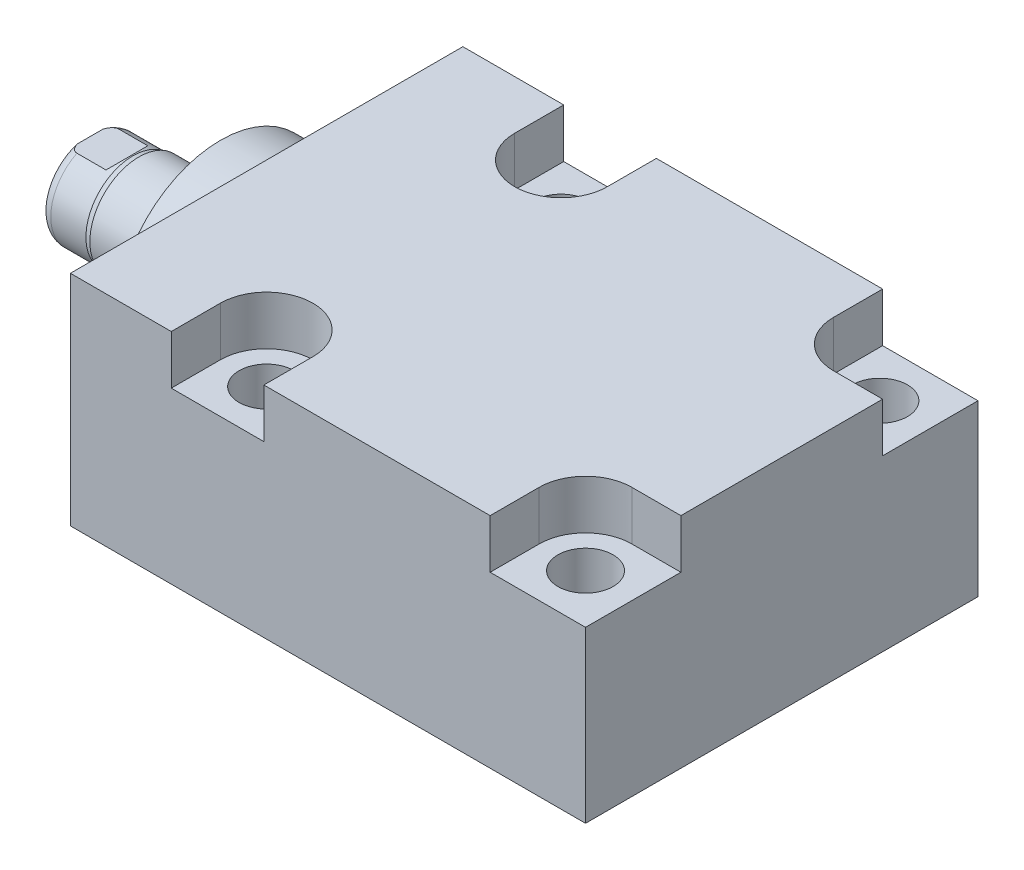
from build123d import *

# Parameters (mm, degrees)
SKETCH1_W          = 50.8
SKETCH1_H          = 28.321
EXTRUDE1_DEPTH     = 66.675
SKETCH5_R          = 13.5001
EXTRUDE2_DEPTH     = 5.969
SKETCH6_W          = 6.35
SKETCH6_H          = 16.891
CUT_EXTRUDE4_DEPTH = 30.48
HOLE2_D            = 7.1374
HOLE2_DEPTH        = 28.321
LPATTERN1_COUNT    = 2
LPATTERN1_PITCH    = 41.275
CUT_EXTRUDE5_DEPTH = 6.35
HOLE3_D            = 2.3876
HOLE3_DEPTH        = 14.224
HOLE3_CBORE_D      = 11.3411
HOLE3_CBORE_DEPTH  = 1.4478
HOLE3_TIP          = 0.717307407
HOLE4_D            = 3.175
HOLE4_DEPTH        = 14.224
HOLE4_TIP          = 0.953866233
SKETCH25_R         = 5.6705
CUT_EXTRUDE6_DEPTH = 1.448
CHAMFER1_SIZE      = 0.635
SKETCH23_R         = 1.4478
LPATTERN3_COUNT    = 2
LPATTERN3_PITCH    = 41.275


with BuildPart() as part:
    # Sketch1 → Extrude1 (new body)
    with BuildSketch(Plane(origin=(0, 0, 0), x_dir=(0, 0, -1), z_dir=(1, 0, 0))):
        with Locations((0, 0.1105)):
            Rectangle(SKETCH1_W, SKETCH1_H)
    extrude(amount=EXTRUDE1_DEPTH)

    # Sketch5 → Extrude2 (add)
    with BuildSketch(Plane.ZY):
        with Locations(Location((0, 0, 0), (0, 0, 180))):  # turned: the seam where the file's is
            Circle(SKETCH5_R)
    extrude(amount=EXTRUDE2_DEPTH)

    # Sketch6 → Revolve1 (revolve)
    with BuildSketch(Plane(origin=(0, 0, 0), x_dir=(0, 0, 1), z_dir=(0, -1, 0))):
        with Locations((-3.175, 14.4145)):
            Rectangle(SKETCH6_W, SKETCH6_H)
    revolve(axis=Axis((5.754582971, 0, 0), (-1, 0, 0)))

    # S2D0001 → Cut-Revolve4 (revolve, cut)
    with BuildSketch(Plane(origin=(-18.511260017, 3.2639, 0), x_dir=(0, 1, 0), z_dir=(0, 0, 1)), mode=Mode.PRIVATE) as cut_revolve4_sk:
        Polygon((-0.7112, 2.786949769), (-0.7112, -11.653260017), (-3.2639, -13.18707692), (-3.2639, 4.348739983), (0.1905, 4.348739983), align=None)
    revolve(cut_revolve4_sk.sketch.rotate(Axis((0, 0, 0), (-1, 0, 0)), 90), axis=Axis((0, 0, 0), (-1, 0, 0)), mode=Mode.SUBTRACT)  # turned: the seam where the file's is

    # Sketch8 → Cut-Revolve5 (revolve, cut)
    with BuildSketch(Plane(origin=(0, 0, 0), x_dir=(0, 0, -1), z_dir=(0, 1, 0)), mode=Mode.PRIVATE) as cut_revolve5_sk:
        with BuildLine():
            Line((-6.35, 16.5354), (-6.096, 17.2974))
            Line((-6.096, 17.2974), (-6.096, 21.844))
            ThreePointArc((-6.096, 21.844), (-5.995678675, 22.387796865), (-5.707922533, 22.86))
            Line((-5.707922533, 22.86), (-6.35, 22.86))
            Line((-6.35, 22.86), (-6.35, 16.5354))
        make_face()
    revolve(cut_revolve5_sk.sketch.rotate(Axis((-12.65936, 0, 0), (-1, 0, 0)), 180), axis=Axis((-12.65936, 0, 0), (-1, 0, 0)), mode=Mode.SUBTRACT)  # turned: the seam where the file's is

    # Sketch12 → Cut-Extrude4 (cut, symmetric)
    with BuildSketch(Plane(origin=(0, 0, 0), x_dir=(0, -1, 0), z_dir=(0, 0, -1))):
        Polygon((5.461, 22.86), (5.461, 18.0848), (6.096, 17.4498), (6.096, 22.86), align=None)
        Polygon((-5.461, 22.86), (-5.461, 18.0848), (-6.096, 17.4498), (-6.096, 22.86), align=None)
    extrude(amount=CUT_EXTRUDE4_DEPTH, both=True, mode=Mode.SUBTRACT)

    # Hole2
    with Locations(Plane(origin=(0, 14.271, 0), x_dir=(-1, 0, 0), z_dir=(0, 1, 0))):
        with Locations((-19.05, -19.05), (-19.05, 19.05)):
            hole2 = Hole(HOLE2_D / 2, depth=HOLE2_DEPTH)

    # LPattern1: Hole2 ×2
    with Locations(*[(i * LPATTERN1_PITCH, 0, 0) for i in range(1, LPATTERN1_COUNT)]):
        add(hole2, mode=Mode.SUBTRACT)

    # Sketch18 → Cut-Extrude5 (cut)
    with BuildSketch(Plane(origin=(0, 14.271, 0), x_dir=(1, 0, 0), z_dir=(0, 1, 0))):
        with BuildLine():
            Line((66.675, -25.4), (54.3306, -25.4))
            Line((54.3306, -25.4), (54.3306, -19.05))
            ThreePointArc((54.3306, -19.05), (56.086319111, -14.811319111), (60.325, -13.0556))
            Line((60.325, -13.0556), (66.675, -13.0556))
            Line((66.675, -13.0556), (66.675, -25.4))
        make_face()
        with BuildLine():
            Line((13.0556, -19.05), (13.0556, -25.4))
            Line((13.0556, -25.4), (25.0444, -25.4))
            Line((25.0444, -25.4), (25.0444, -19.05))
            ThreePointArc((25.0444, -19.05), (19.05, -13.0556), (13.0556, -19.05))
        make_face()
        with BuildLine():
            Line((66.675, 13.0556), (66.675, 25.4))
            Line((66.675, 25.4), (54.3306, 25.4))
            Line((54.3306, 25.4), (54.3306, 19.05))
            ThreePointArc((54.3306, 19.05), (56.086319111, 14.811319111), (60.325, 13.0556))
            Line((60.325, 13.0556), (66.675, 13.0556))
        make_face()
        with BuildLine():
            Line((25.0444, 25.4), (13.0556, 25.4))
            Line((13.0556, 25.4), (13.0556, 19.05))
            ThreePointArc((13.0556, 19.05), (19.05, 13.0556), (25.0444, 19.05))
            Line((25.0444, 19.05), (25.0444, 25.4))
        make_face()
    extrude(amount=-CUT_EXTRUDE5_DEPTH, mode=Mode.SUBTRACT)

    # Hole3
    with Locations(Plane.XZ.offset(14.05)):
        with Locations((12.7, 0)):
            CounterBoreHole(HOLE3_D / 2, HOLE3_CBORE_D / 2, HOLE3_CBORE_DEPTH, depth=HOLE3_DEPTH)
            with Locations((0, 0, -(HOLE3_DEPTH + HOLE3_TIP / 2))):  # 118° drill point
                Cone(0, HOLE3_D / 2, HOLE3_TIP, mode=Mode.SUBTRACT)

    # Hole4
    with Locations(Plane.XZ.offset(14.05)):
        with Locations((55.425, 0)):
            Hole(HOLE4_D / 2, depth=HOLE4_DEPTH)
            with Locations((0, 0, -(HOLE4_DEPTH + HOLE4_TIP / 2))):  # 118° drill point
                Cone(0, HOLE4_D / 2, HOLE4_TIP, mode=Mode.SUBTRACT)

    # Sketch25 → Cut-Extrude6 (cut)
    with BuildSketch(Plane.XZ.offset(14.05)):
        with Locations(Location((53.975, 0, 0), (0, 0, 270))):  # turned: the seam where the file's is
            Circle(SKETCH25_R)
    extrude(amount=-CUT_EXTRUDE6_DEPTH, mode=Mode.SUBTRACT)

    # Chamfer1
    chamfer1_edges = [part.edges().sort_by_distance(p)[0] for p in [
        (13.8938, -12.6022, 0),
        (57.0125, -12.602, 0),
    ]]
    chamfer(chamfer1_edges, length=CHAMFER1_SIZE)


with BuildPart() as body_2:
    # Sketch23 → Revolve2 (revolve)
    with BuildSketch(Plane.XY, mode=Mode.PRIVATE) as revolve2_sk:
        with Locations((8.47725, -14.05)):
            Circle(SKETCH23_R)
    revolve(revolve2_sk.sketch.rotate(Axis((12.7, -12.6022, 0), (0, -1, 0)), 90), axis=Axis((12.7, -12.6022, 0), (0, -1, 0)))  # turned: the seam where the file's is


with BuildPart() as lpattern3_1:
    # LPattern3: pattern copy
    add(body_2.part.moved(Location(Vector(1, 0, 0) * (1 * LPATTERN3_PITCH))))


solid = Compound([part.part, body_2.part, lpattern3_1.part])
